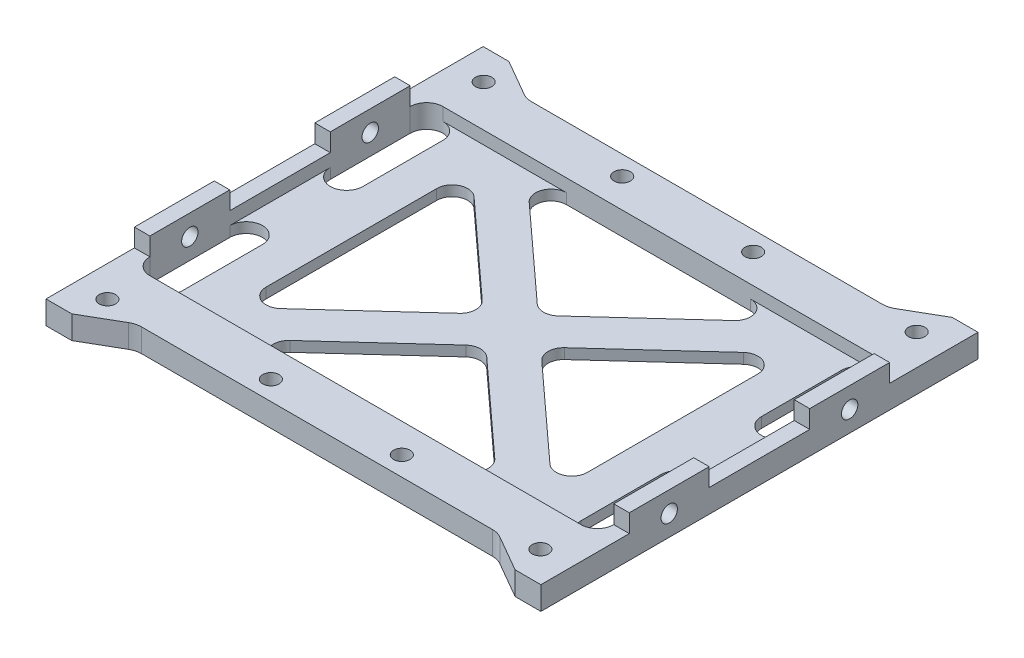
from build123d import *

# Parameters (mm, degrees)
SKETCH1_R           = 1.5875
BOSS_EXTRUDE1_DEPTH = 2
SKETCH2_R           = 1.5875
BOSS_EXTRUDE2_DEPTH = 2.5
BOSS_EXTRUDE3_START = -3
SKETCH3_W           = 15.5
SKETCH3_H           = 3.5
BOSS_EXTRUDE3_DEPTH = 3
SKETCH4_R           = 1.5875
CUT_EXTRUDE1_DEPTH  = 5
CUT_EXTRUDE2_DEPTH  = 65.325422657


with BuildPart() as part:
    # Sketch1 → Boss-Extrude1 (new body)
    with BuildSketch(Plane(origin=(0, 0, 0), x_dir=(1, 0, 0), z_dir=(0, 1, 0))):
        with BuildLine():
            Line((-48, -42.4), (-43, -42.4))
            Line((-43, -42.4), (-36.009266938, -38.363898385))
            ThreePointArc((-36.009266938, -38.363898385), (-35.044543118, -37.964296695), (-34.009266938, -37.828))
            Line((-34.009266938, -37.828), (34.009266938, -37.828))
            ThreePointArc((34.009266938, -37.828), (35.044543118, -37.964296695), (36.009266938, -38.363898385))
            Line((36.009266938, -38.363898385), (43, -42.4))
            Line((43, -42.4), (48, -42.4))
            Line((48, -42.4), (48, 42.4))
            Line((48, 42.4), (43, 42.4))
            Line((43, 42.4), (36.009266938, 38.363898385))
            ThreePointArc((36.009266938, 38.363898385), (35.044543118, 37.964296695), (34.009266938, 37.828))
            Line((34.009266938, 37.828), (-34.009266938, 37.828))
            ThreePointArc((-34.009266938, 37.828), (-35.044543118, 37.964296695), (-36.009266938, 38.363898385))
            Line((-36.009266938, 38.363898385), (-43, 42.4))
            Line((-43, 42.4), (-48, 42.4))
            Line((-48, 42.4), (-48, -42.4))
        make_face()
        with Locations(Location((-12.7, -34.078, 0), (0, 0, 270))):
            Circle(SKETCH1_R, mode=Mode.SUBTRACT)
        with Locations(Location((12.7, -34.078, 0), (0, 0, 270))):
            Circle(SKETCH1_R, mode=Mode.SUBTRACT)
        with Locations(Location((-12.7, 34.078, 0), (0, 0, 270))):
            Circle(SKETCH1_R, mode=Mode.SUBTRACT)
        with Locations(Location((12.7, 34.078, 0), (0, 0, 270))):
            Circle(SKETCH1_R, mode=Mode.SUBTRACT)
        with Locations(Location((-42, 36.5, 0), (0, 0, 270))):
            Circle(SKETCH1_R, mode=Mode.SUBTRACT)
        with Locations(Location((42, 36.5, 0), (0, 0, 270))):
            Circle(SKETCH1_R, mode=Mode.SUBTRACT)
        with Locations(Location((42, -36.5, 0), (0, 0, 270))):
            Circle(SKETCH1_R, mode=Mode.SUBTRACT)
        with Locations(Location((-42, -36.5, 0), (0, 0, 270))):
            Circle(SKETCH1_R, mode=Mode.SUBTRACT)
        with BuildLine():
            Line((-38.65, 25.25), (-38.65, 9.75))
            ThreePointArc((-38.65, 9.75), (-41.825, 6.575), (-45, 9.75))
            Line((-45, 9.75), (-45, 25.25))
            ThreePointArc((-45, 25.25), (-41.825, 28.425), (-38.65, 25.25))
        make_face(mode=Mode.SUBTRACT)
        with BuildLine():
            Line((-38.65, -9.75), (-38.65, -25.25))
            ThreePointArc((-38.65, -25.25), (-41.825, -28.425), (-45, -25.25))
            Line((-45, -25.25), (-45, -9.75))
            ThreePointArc((-45, -9.75), (-41.825, -6.575), (-38.65, -9.75))
        make_face(mode=Mode.SUBTRACT)
        with BuildLine():
            Line((45, 25.25), (45, 9.75))
            ThreePointArc((45, 9.75), (41.825, 6.575), (38.65, 9.75))
            Line((38.65, 9.75), (38.65, 25.25))
            ThreePointArc((38.65, 25.25), (41.825, 28.425), (45, 25.25))
        make_face(mode=Mode.SUBTRACT)
        with BuildLine():
            Line((45, -9.75), (45, -25.25))
            ThreePointArc((45, -25.25), (41.825, -28.425), (38.65, -25.25))
            Line((38.65, -25.25), (38.65, -9.75))
            ThreePointArc((38.65, -9.75), (41.825, -6.575), (45, -9.75))
        make_face(mode=Mode.SUBTRACT)
    extrude(amount=BOSS_EXTRUDE1_DEPTH)

    # Sketch2 → Boss-Extrude2 (add)
    with BuildSketch(Plane(origin=(0, 2, 0), x_dir=(1, 0, 0), z_dir=(0, 1, 0))):
        with BuildLine():
            Line((48, -42.4), (48, 42.4))
            Line((48, 42.4), (43, 42.4))
            Line((43, 42.4), (36.009266938, 38.363898385))
            ThreePointArc((36.009266938, 38.363898385), (35.044543118, 37.964296695), (34.009266938, 37.828))
            Line((34.009266938, 37.828), (-34.009266938, 37.828))
            ThreePointArc((-34.009266938, 37.828), (-35.044543118, 37.964296695), (-36.009266938, 38.363898385))
            Line((-36.009266938, 38.363898385), (-43, 42.4))
            Line((-43, 42.4), (-48, 42.4))
            Line((-48, 42.4), (-48, -42.4))
            Line((-48, -42.4), (-43, -42.4))
            Line((-43, -42.4), (-36.009266938, -38.363898385))
            ThreePointArc((-36.009266938, -38.363898385), (-35.044543118, -37.964296695), (-34.009266938, -37.828))
            Line((-34.009266938, -37.828), (34.009266938, -37.828))
            ThreePointArc((34.009266938, -37.828), (35.044543118, -37.964296695), (36.009266938, -38.363898385))
            Line((36.009266938, -38.363898385), (43, -42.4))
            Line((43, -42.4), (48, -42.4))
        make_face()
        with Locations((-42, -36.5)):
            Circle(SKETCH2_R, mode=Mode.SUBTRACT)
        with Locations((-12.7, -34.078)):
            Circle(SKETCH2_R, mode=Mode.SUBTRACT)
        with Locations((12.7, -34.078)):
            Circle(SKETCH2_R, mode=Mode.SUBTRACT)
        with Locations((42, -36.5)):
            Circle(SKETCH2_R, mode=Mode.SUBTRACT)
        with Locations((-42, 36.5)):
            Circle(SKETCH2_R, mode=Mode.SUBTRACT)
        with Locations((-12.7, 34.078)):
            Circle(SKETCH2_R, mode=Mode.SUBTRACT)
        with BuildLine():
            Line((45, 9.75), (45, -9.75))
            Line((45, -9.75), (45, -25.25))
            ThreePointArc((45, -25.25), (44.07006403, -27.49506403), (41.825, -28.425))
            Line((41.825, -28.425), (-41.825, -28.425))
            ThreePointArc((-41.825, -28.425), (-44.07006403, -27.49506403), (-45, -25.25))
            Line((-45, -25.25), (-45, -9.75))
            Line((-45, -9.75), (-45, 9.75))
            Line((-45, 9.75), (-45, 25.25))
            ThreePointArc((-45, 25.25), (-44.07006403, 27.49506403), (-41.825, 28.425))
            Line((-41.825, 28.425), (41.825, 28.425))
            ThreePointArc((41.825, 28.425), (44.07006403, 27.49506403), (45, 25.25))
            Line((45, 25.25), (45, 9.75))
        make_face(mode=Mode.SUBTRACT)
        with Locations((12.7, 34.078)):
            Circle(SKETCH2_R, mode=Mode.SUBTRACT)
        with Locations((42, 36.5)):
            Circle(SKETCH2_R, mode=Mode.SUBTRACT)
    extrude(amount=BOSS_EXTRUDE2_DEPTH)

    # Sketch3 → Boss-Extrude3 (add)
    with BuildSketch(Plane(origin=(48, 0, 0), x_dir=(0, 0, -1), z_dir=(1, 0, 0)).offset(BOSS_EXTRUDE3_START)):
        with Locations((-17.5, 6.25)):
            Rectangle(SKETCH3_W, SKETCH3_H)
        with Locations((17.5, 6.25)):
            Rectangle(SKETCH3_W, SKETCH3_H)
    boss_extrude3 = extrude(amount=BOSS_EXTRUDE3_DEPTH)

    # Sketch4 → Cut-Extrude1 (cut)
    with BuildSketch(Plane(origin=(48, 0, 0), x_dir=(0, 0, -1), z_dir=(1, 0, 0))):
        with Locations((-17.5, 4)):
            Circle(SKETCH4_R)
        with Locations((17.5, 4)):
            Circle(SKETCH4_R)
    cut_extrude1 = extrude(amount=-CUT_EXTRUDE1_DEPTH, mode=Mode.SUBTRACT)

    # Mirror1: Boss-Extrude3, Cut-Extrude1 across plane
    add(boss_extrude3.mirror(Plane(origin=(0, 0, 0), x_dir=(0, 0, 1), z_dir=(1, 0, 0))))
    add(cut_extrude1.mirror(Plane(origin=(0, 0, 0), x_dir=(0, 0, 1), z_dir=(1, 0, 0))), mode=Mode.SUBTRACT)

    # Sketch5 → Cut-Extrude2 (cut, through all)
    with BuildSketch(Plane(origin=(0, 2, 0), x_dir=(1, 0, 0), z_dir=(0, 1, 0))):
        with BuildLine():
            Line((-26.127824556, -18.76552712), (-7.991792465, -2.216033952))
            ThreePointArc((-7.991792465, -2.216033952), (-7.013967909, 0), (-7.991792465, 2.216033952))
            Line((-7.991792465, 2.216033952), (-26.127824556, 18.76552712))
            ThreePointArc((-26.127824556, 18.76552712), (-29.361089111, 19.294172233), (-31.15, 16.549493168))
            Line((-31.15, 16.549493168), (-31.15, -16.549493168))
            ThreePointArc((-31.15, -16.549493168), (-29.361089111, -19.294172233), (-26.127824556, -18.76552712))
        make_face()
        with BuildLine():
            Line((19.87060859, 23.208966048), (2.022175444, 6.921912688))
            ThreePointArc((2.022175444, 6.921912688), (0, 6.137946639), (-2.022175444, 6.921912688))
            Line((-2.022175444, 6.921912688), (-19.87060859, 23.208966048))
            ThreePointArc((-19.87060859, 23.208966048), (-20.645583648, 26.509411856), (-17.848433147, 28.425))
            Line((-17.848433147, 28.425), (17.848433147, 28.425))
            ThreePointArc((17.848433147, 28.425), (20.645583648, 26.509411856), (19.87060859, 23.208966048))
        make_face()
        with BuildLine():
            Line((-19.87060859, -23.208966048), (-2.022175444, -6.921912688))
            ThreePointArc((-2.022175444, -6.921912688), (0, -6.137946639), (2.022175444, -6.921912688))
            Line((2.022175444, -6.921912688), (19.87060859, -23.208966048))
            ThreePointArc((19.87060859, -23.208966048), (20.645583648, -26.509411856), (17.848433147, -28.425))
            Line((17.848433147, -28.425), (-17.848433147, -28.425))
            ThreePointArc((-17.848433147, -28.425), (-20.645583648, -26.509411856), (-19.87060859, -23.208966048))
        make_face()
        with BuildLine():
            Line((7.991792465, 2.216033952), (26.127824556, 18.76552712))
            ThreePointArc((26.127824556, 18.76552712), (29.361089111, 19.294172233), (31.15, 16.549493168))
            Line((31.15, 16.549493168), (31.15, -16.549493168))
            ThreePointArc((31.15, -16.549493168), (29.361089111, -19.294172233), (26.127824556, -18.76552712))
            Line((26.127824556, -18.76552712), (7.991792465, -2.216033952))
            ThreePointArc((7.991792465, -2.216033952), (7.013967909, 0), (7.991792465, 2.216033952))
        make_face()
    extrude(amount=-CUT_EXTRUDE2_DEPTH, mode=Mode.SUBTRACT)


solid = part.part
